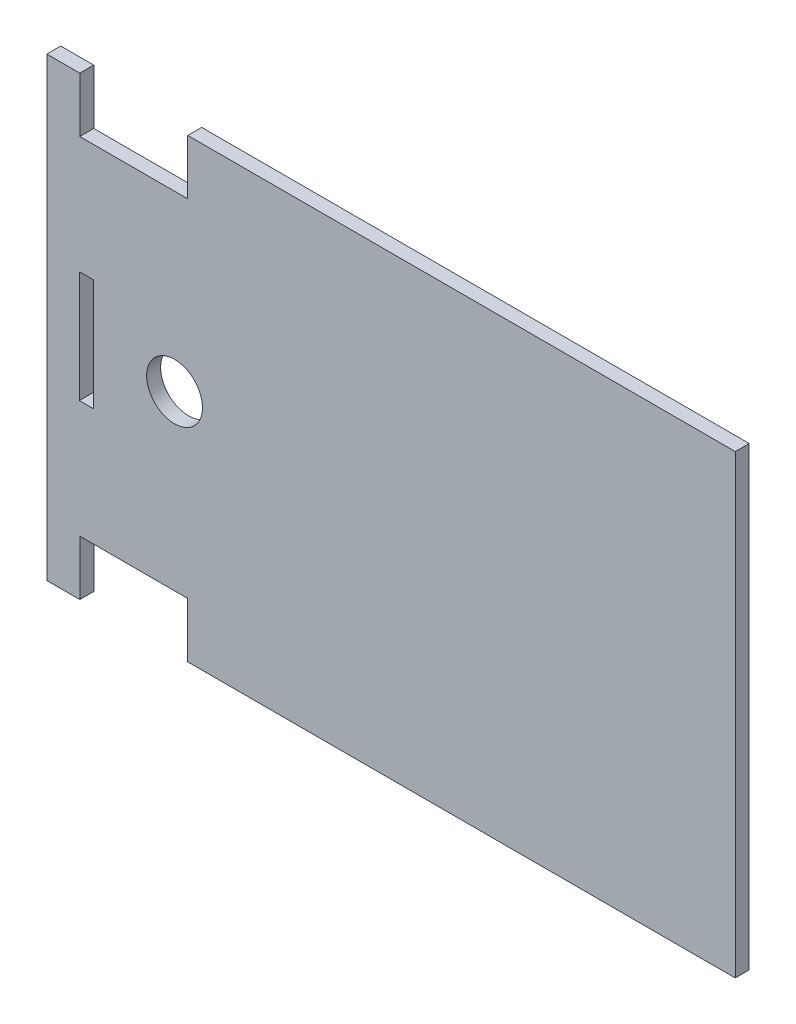
from build123d import *

# Parameters (mm, degrees)
MODEL_R                 = 6
MODEL_W                 = 3
MODEL_H                 = 24
SALIENTE_EXTRUIR2_DEPTH = 3


with BuildPart() as part:
    # Model → Saliente-Extruir2 (new body)
    with BuildSketch(Plane.XY):
        Polygon((-39.51128192, -9.185059482), (-32.41128192, -9.185059482), (-32.41128192, 2.614940518), (-9.21128192, 2.614940518), (-9.21128192, -9.185059482), (16.002025332, -9.185059482), (50.517196398, -9.185059482), (78.48871808, -9.185059482), (89.48871808, -9.185059482), (96.48871808, -9.185059482), (103.48871808, -9.185059482), (108.48871808, -9.185059482), (108.48871808, 88.814940518), (24.48871808, 88.814940518), (2.28871808, 88.814940518), (-0.51128192, 88.814940518), (-1.51128192, 88.814940518), (-9.21128192, 88.814940518), (-9.21128192, 77.014940518), (-32.41128192, 77.014940518), (-32.41128192, 88.814940518), (-39.51128192, 88.814940518), align=None)
        with Locations((-12.040844912, 39.714244751)):
            Circle(MODEL_R, mode=Mode.SUBTRACT)
        with Locations((-31.01128192, 39.814940518)):
            Rectangle(MODEL_W, MODEL_H, mode=Mode.SUBTRACT)
    extrude(amount=SALIENTE_EXTRUIR2_DEPTH)


solid = part.part
